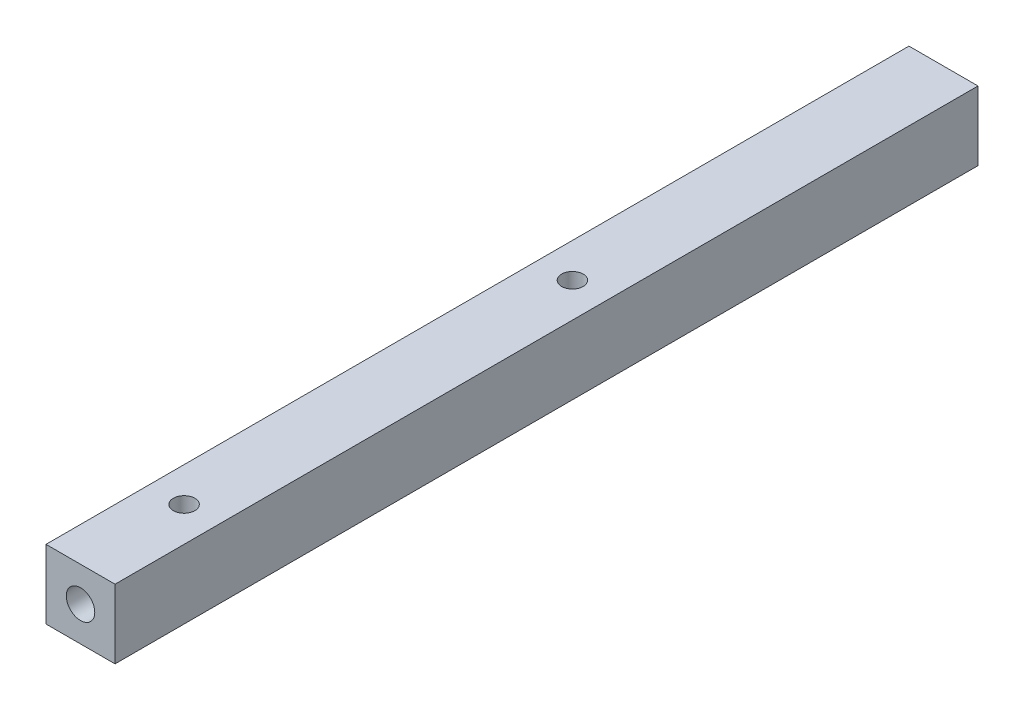
from build123d import *

# Parameters (mm, degrees)
SKETCH1_W                       = 8
SKETCH1_H                       = 8
EXTRUDE1_DEPTH                  = 100
M3_TAPPED_HOLE1_D               = 2.5
M4_TAPPED_HOLE1_D               = 3.3
M4_TAPPED_HOLE1_DEPTH           = 10
M4_TAPPED_HOLE1_TIP             = 0.991420021
M4_TAPPED_HOLE1_ON_FACE_2_D     = 3.3
M4_TAPPED_HOLE1_ON_FACE_2_DEPTH = 10
M4_TAPPED_HOLE1_ON_FACE_2_TIP   = 0.991420021


with BuildPart() as part:
    # Sketch1 → Extrude1 (new body)
    with BuildSketch(Plane.XY):
        with Locations((4, 4)):
            Rectangle(SKETCH1_W, SKETCH1_H)
    extrude(amount=EXTRUDE1_DEPTH)

    # M3 Tapped Hole1 (through all)
    with Locations(Plane(origin=(4, 8, 88), x_dir=(0, 0, 1), z_dir=(0, 1, 0))):
        with Locations((0, 0), (-45, 0)):
            Hole(M3_TAPPED_HOLE1_D / 2)

    # M4 Tapped Hole1
    with Locations(Plane(origin=(4, 4, 100), x_dir=(1, 0, 0), z_dir=(0, 0, 1))):
        with Locations((0, 0)):
            Hole(M4_TAPPED_HOLE1_D / 2, depth=M4_TAPPED_HOLE1_DEPTH)
            with Locations((0, 0, -(M4_TAPPED_HOLE1_DEPTH + M4_TAPPED_HOLE1_TIP / 2))):  # 118° drill point
                Cone(0, M4_TAPPED_HOLE1_D / 2, M4_TAPPED_HOLE1_TIP, mode=Mode.SUBTRACT)

    # M4 Tapped Hole1 on face 2
    with Locations(Plane(origin=(4, 4, 0), x_dir=(-1, 0, 0), z_dir=(0, 0, -1))):
        with Locations((0, 0)):
            Hole(M4_TAPPED_HOLE1_ON_FACE_2_D / 2, depth=M4_TAPPED_HOLE1_ON_FACE_2_DEPTH)
            with Locations((0, 0, -(M4_TAPPED_HOLE1_ON_FACE_2_DEPTH + M4_TAPPED_HOLE1_ON_FACE_2_TIP / 2))):  # 118° drill point
                Cone(0, M4_TAPPED_HOLE1_ON_FACE_2_D / 2, M4_TAPPED_HOLE1_ON_FACE_2_TIP, mode=Mode.SUBTRACT)


solid = part.part
